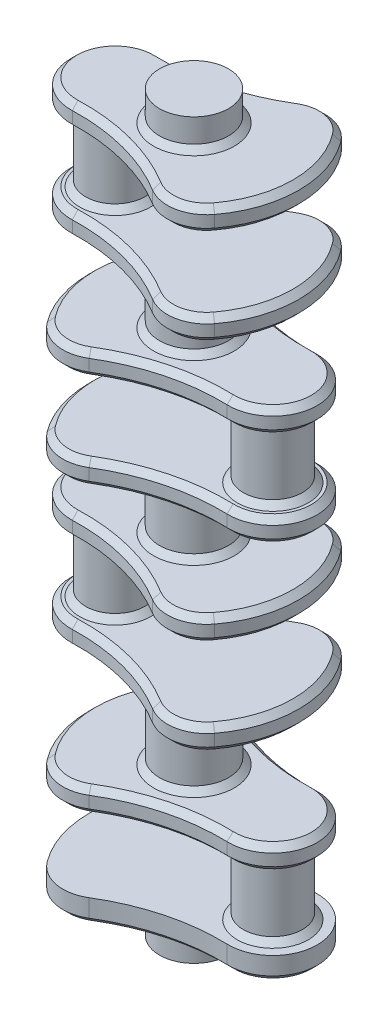
from build123d import *

# Parameters (mm, degrees)
SALIENTE_EXTRUIR1_DEPTH  = 12
CROQUIS3_R               = 17.5
SALIENTE_EXTRUIR2_DEPTH  = 15
SALIENTE_EXTRUIR3_DEPTH  = 12
CROQUIS6_R               = 15
SALIENTE_EXTRUIR4_DEPTH  = 36
SALIENTE_EXTRUIR6_DEPTH  = 12
CROQUIS9_R               = 17.5
SALIENTE_EXTRUIR7_DEPTH  = 42
SALIENTE_EXTRUIR8_DEPTH  = 12
CROQUIS11_R              = 15
SALIENTE_EXTRUIR10_DEPTH = 36
SALIENTE_EXTRUIR11_DEPTH = 12
CROQUIS13_R              = 17.5
SALIENTE_EXTRUIR12_DEPTH = 30
SALIENTE_EXTRUIR13_DEPTH = 12
CROQUIS15_R              = 15
SALIENTE_EXTRUIR14_DEPTH = 36
SALIENTE_EXTRUIR16_DEPTH = 12
CROQUIS18_R              = 17.5
SALIENTE_EXTRUIR17_DEPTH = 30
SALIENTE_EXTRUIR18_DEPTH = 12
CROQUIS20_R              = 15
SALIENTE_EXTRUIR19_DEPTH = 36
CROQUIS21_R              = 17.5
SALIENTE_EXTRUIR20_DEPTH = 15
CHAFL_N2_SIZE            = 3


with BuildPart() as part:
    # Croquis2 → Saliente-Extruir1 (new body)
    with BuildSketch(Plane(origin=(0, 0, 0), x_dir=(1, 0, 0), z_dir=(0, 1, 0))):
        with BuildLine():
            ThreePointArc((-16.08221071, 37.072482722), (-30.241727041, 39.646869439), (-42.463783007, 32.048138118))
            ThreePointArc((-42.463783007, 32.048138118), (-53.200150602, 0), (-42.463783007, -32.048138118))
            ThreePointArc((-42.463783007, -32.048138118), (-30.241727041, -39.646869439), (-16.08221071, -37.072482722))
            ThreePointArc((-16.08221071, -37.072482722), (10.526396699, -25.735608218), (39.266543299, -22.488042184))
            ThreePointArc((39.266543299, -22.488042184), (62.5, 0), (39.266543299, 22.488042184))
            ThreePointArc((39.266543299, 22.488042184), (10.526396699, 25.735608218), (-16.08221071, 37.072482722))
        make_face()
    extrude(amount=SALIENTE_EXTRUIR1_DEPTH)

    # Croquis3 → Saliente-Extruir2 (add)
    with BuildSketch(Plane.XZ):
        Circle(CROQUIS3_R)
    extrude(amount=SALIENTE_EXTRUIR2_DEPTH)



with BuildPart() as body_2:
    # Croquis4 → Saliente-Extruir3 (new body)
    with BuildSketch(Plane(origin=(0, 48, 0), x_dir=(1, 0, 0), z_dir=(0, 1, 0))):
        with BuildLine():
            ThreePointArc((-16.08221071, 37.072482722), (-30.241727041, 39.646869439), (-42.463783007, 32.048138118))
            ThreePointArc((-42.463783007, 32.048138118), (-53.200150602, 0), (-42.463783007, -32.048138118))
            ThreePointArc((-42.463783007, -32.048138118), (-30.241727041, -39.646869439), (-16.08221071, -37.072482722))
            ThreePointArc((-16.08221071, -37.072482722), (10.526396699, -25.735608218), (39.266543299, -22.488042184))
            ThreePointArc((39.266543299, -22.488042184), (62.5, 0), (39.266543299, 22.488042184))
            ThreePointArc((39.266543299, 22.488042184), (10.526396699, 25.735608218), (-16.08221071, 37.072482722))
        make_face()
    extrude(amount=SALIENTE_EXTRUIR3_DEPTH)


with BuildPart() as part_1:
    add(part.part)

    add(body_2.part)  # Saliente-Extruir4 merges body 2
    # Croquis6 → Saliente-Extruir4 (add)
    with BuildSketch(Plane(origin=(0, 48, 0), x_dir=(-1, 0, 0), z_dir=(0, -1, 0))):
        with Locations((-40, 0)):
            Circle(CROQUIS6_R)
    extrude(amount=SALIENTE_EXTRUIR4_DEPTH)



with BuildPart() as body_2_2:
    # Croquis8 → Saliente-Extruir6 (new body)
    with BuildSketch(Plane(origin=(0, 102, 0), x_dir=(1, 0, 0), z_dir=(0, 1, 0))):
        with BuildLine():
            ThreePointArc((-39.266543299, 22.488042184), (-62.5, 0), (-39.266543299, -22.488042184))
            ThreePointArc((-39.266543299, -22.488042184), (-10.526396699, -25.735608218), (16.08221071, -37.072482722))
            ThreePointArc((16.08221071, -37.072482722), (30.241727041, -39.646869439), (42.463783007, -32.048138118))
            ThreePointArc((42.463783007, -32.048138118), (53.200150602, 0), (42.463783007, 32.048138118))
            ThreePointArc((42.463783007, 32.048138118), (30.241727041, 39.646869439), (16.08221071, 37.072482722))
            ThreePointArc((16.08221071, 37.072482722), (-10.526396699, 25.735608218), (-39.266543299, 22.488042184))
        make_face()
    extrude(amount=SALIENTE_EXTRUIR6_DEPTH)


with BuildPart() as part_2:
    add(part_1.part)

    add(body_2_2.part)  # Saliente-Extruir7 merges body 2 2
    # Croquis9 → Saliente-Extruir7 (add)
    with BuildSketch(Plane.XZ.offset(-102)):
        Circle(CROQUIS9_R)
    extrude(amount=SALIENTE_EXTRUIR7_DEPTH)



with BuildPart() as body_2_3:
    # Croquis10 → Saliente-Extruir8 (new body)
    with BuildSketch(Plane(origin=(0, 150, 0), x_dir=(-1, 0, 0), z_dir=(0, -1, 0))):
        with BuildLine():
            ThreePointArc((-42.463783007, 32.048138118), (-53.200150602, 0), (-42.463783007, -32.048138118))
            ThreePointArc((-42.463783007, -32.048138118), (-30.241727041, -39.646869439), (-16.08221071, -37.072482722))
            ThreePointArc((-16.08221071, -37.072482722), (10.526396699, -25.735608218), (39.266543299, -22.488042184))
            ThreePointArc((39.266543299, -22.488042184), (62.5, 0), (39.266543299, 22.488042184))
            ThreePointArc((39.266543299, 22.488042184), (10.526396699, 25.735608218), (-16.08221071, 37.072482722))
            ThreePointArc((-16.08221071, 37.072482722), (-30.241727041, 39.646869439), (-42.463783007, 32.048138118))
        make_face()
    extrude(amount=-SALIENTE_EXTRUIR8_DEPTH)


with BuildPart() as part_3:
    add(part_2.part)

    add(body_2_3.part)  # Saliente-Extruir10 merges body 2 3
    # Croquis11 → Saliente-Extruir10 (add)
    with BuildSketch(Plane.XZ.offset(-150)):
        with Locations((-40, 0)):
            Circle(CROQUIS11_R)
    extrude(amount=SALIENTE_EXTRUIR10_DEPTH)



with BuildPart() as body_2_4:
    # Croquis12 → Saliente-Extruir11 (new body)
    with BuildSketch(Plane(origin=(0, 192, 0), x_dir=(-1, 0, 0), z_dir=(0, -1, 0))):
        with BuildLine():
            ThreePointArc((-39.266543299, 22.488042184), (-10.526396699, 25.735608218), (16.08221071, 37.072482722))
            ThreePointArc((16.08221071, 37.072482722), (30.241727041, 39.646869439), (42.463783007, 32.048138118))
            ThreePointArc((42.463783007, 32.048138118), (53.200150602, 0), (42.463783007, -32.048138118))
            ThreePointArc((42.463783007, -32.048138118), (30.241727041, -39.646869439), (16.08221071, -37.072482722))
            ThreePointArc((16.08221071, -37.072482722), (-10.526396699, -25.735608218), (-39.266543299, -22.488042184))
            ThreePointArc((-39.266543299, -22.488042184), (-62.5, 0), (-39.266543299, 22.488042184))
        make_face()
    extrude(amount=-SALIENTE_EXTRUIR11_DEPTH)


with BuildPart() as part_4:
    add(part_3.part)

    add(body_2_4.part)  # Saliente-Extruir12 merges body 2 4
    # Croquis13 → Saliente-Extruir12 (add)
    with BuildSketch(Plane.XZ.offset(-192)):
        Circle(CROQUIS13_R)
    extrude(amount=SALIENTE_EXTRUIR12_DEPTH)



with BuildPart() as body_2_5:
    # Croquis14 → Saliente-Extruir13 (new body)
    with BuildSketch(Plane(origin=(0, 240, 0), x_dir=(-1, 0, 0), z_dir=(0, -1, 0))):
        with BuildLine():
            ThreePointArc((-39.266543299, 22.488042184), (-62.5, 0), (-39.266543299, -22.488042184))
            ThreePointArc((-39.266543299, -22.488042184), (-10.526396699, -25.735608218), (16.08221071, -37.072482722))
            ThreePointArc((16.08221071, -37.072482722), (30.241727041, -39.646869439), (42.463783007, -32.048138118))
            ThreePointArc((42.463783007, -32.048138118), (53.200150602, 0), (42.463783007, 32.048138118))
            ThreePointArc((42.463783007, 32.048138118), (30.241727041, 39.646869439), (16.08221071, 37.072482722))
            ThreePointArc((16.08221071, 37.072482722), (-10.526396699, 25.735608218), (-39.266543299, 22.488042184))
        make_face()
    extrude(amount=-SALIENTE_EXTRUIR13_DEPTH)


with BuildPart() as part_5:
    add(part_4.part)

    add(body_2_5.part)  # Saliente-Extruir14 merges body 2 5
    # Croquis15 → Saliente-Extruir14 (add)
    with BuildSketch(Plane.XZ.offset(-240)):
        with Locations((40, 0)):
            Circle(CROQUIS15_R)
    extrude(amount=SALIENTE_EXTRUIR14_DEPTH)



with BuildPart() as body_2_6:
    # Croquis17 → Saliente-Extruir16 (new body)
    with BuildSketch(Plane(origin=(0, 282, 0), x_dir=(-1, 0, 0), z_dir=(0, -1, 0))):
        with BuildLine():
            ThreePointArc((-16.08221071, 37.072482722), (-30.241727041, 39.646869439), (-42.463783007, 32.048138118))
            ThreePointArc((-42.463783007, 32.048138118), (-53.200150602, 0), (-42.463783007, -32.048138118))
            ThreePointArc((-42.463783007, -32.048138118), (-30.241727041, -39.646869439), (-16.08221071, -37.072482722))
            ThreePointArc((-16.08221071, -37.072482722), (10.526396699, -25.735608218), (39.266543299, -22.488042184))
            ThreePointArc((39.266543299, -22.488042184), (62.5, 0), (39.266543299, 22.488042184))
            ThreePointArc((39.266543299, 22.488042184), (10.526396699, 25.735608218), (-16.08221071, 37.072482722))
        make_face()
    extrude(amount=-SALIENTE_EXTRUIR16_DEPTH)


with BuildPart() as part_6:
    add(part_5.part)

    add(body_2_6.part)  # Saliente-Extruir17 merges body 2 6
    # Croquis18 → Saliente-Extruir17 (add)
    with BuildSketch(Plane.XZ.offset(-282)):
        Circle(CROQUIS18_R)
    extrude(amount=SALIENTE_EXTRUIR17_DEPTH)



with BuildPart() as body_2_7:
    # Croquis19 → Saliente-Extruir18 (new body)
    with BuildSketch(Plane(origin=(0, 330, 0), x_dir=(-1, 0, 0), z_dir=(0, -1, 0))):
        with BuildLine():
            ThreePointArc((-16.08221071, 37.072482722), (10.526396699, 25.735608218), (39.266543299, 22.488042184))
            ThreePointArc((39.266543299, 22.488042184), (62.5, 0), (39.266543299, -22.488042184))
            ThreePointArc((39.266543299, -22.488042184), (10.526396699, -25.735608218), (-16.08221071, -37.072482722))
            ThreePointArc((-16.08221071, -37.072482722), (-30.241727041, -39.646869439), (-42.463783007, -32.048138118))
            ThreePointArc((-42.463783007, -32.048138118), (-53.200150602, 0), (-42.463783007, 32.048138118))
            ThreePointArc((-42.463783007, 32.048138118), (-30.241727041, 39.646869439), (-16.08221071, 37.072482722))
        make_face()
    extrude(amount=-SALIENTE_EXTRUIR18_DEPTH)


with BuildPart() as part_7:
    add(part_6.part)

    add(body_2_7.part)  # Saliente-Extruir19 merges body 2 7
    # Croquis20 → Saliente-Extruir19 (add)
    with BuildSketch(Plane.XZ.offset(-330)):
        with Locations((-40, 0)):
            Circle(CROQUIS20_R)
    extrude(amount=SALIENTE_EXTRUIR19_DEPTH)

    # Croquis21 → Saliente-Extruir20 (add)
    with BuildSketch(Plane(origin=(0, 342, 0), x_dir=(1, 0, 0), z_dir=(0, 1, 0))):
        Circle(CROQUIS21_R)
    extrude(amount=SALIENTE_EXTRUIR20_DEPTH)

    # Chaflán2
    chafl_n2_edges = [part_7.edges().sort_by_distance(p)[0] for p in [
        (-17.5, 252, 0),
        (-10.526396699, 282, -25.735608218),
        (30.241727041, 282, -39.646869439),
        (53.200150602, 282, 0),
        (30.241727041, 282, 39.646869439),
        (-10.526396699, 282, 25.735608218),
        (-62.5, 282, 0),
        (-10.526396699, 294, -25.735608218),
        (-62.5, 294, 0),
        (-10.526396699, 294, 25.735608218),
        (30.241727041, 294, 39.646869439),
        (53.200150602, 294, 0),
        (30.241727041, 294, -39.646869439),
        (-17.5, 282, 0),
        (-55, 294, 0),
        (30.241727041, 330, -39.646869439),
        (53.200150602, 330, 0),
        (30.241727041, 330, 39.646869439),
        (-10.526396699, 330, 25.735608218),
        (-62.5, 330, 0),
        (-10.526396699, 330, -25.735608218),
        (30.241727041, 342, -39.646869439),
        (-10.526396699, 342, -25.735608218),
        (-62.5, 342, 0),
        (-10.526396699, 342, 25.735608218),
        (30.241727041, 342, 39.646869439),
        (53.200150602, 342, 0),
        (-55, 330, 0),
        (-17.5, 342, 0),
        (-17.5, 0, 0),
        (55, 12, 0),
        (55, 48, 0),
        (10.526396699, 48, -25.735608218),
        (-30.241727041, 48, -39.646869439),
        (-53.200150602, 48, 0),
        (-30.241727041, 48, 39.646869439),
        (10.526396699, 48, 25.735608218),
        (62.5, 48, 0),
        (10.526396699, 60, -25.735608218),
        (-30.241727041, 60, -39.646869439),
        (-53.200150602, 60, 0),
        (-30.241727041, 60, 39.646869439),
        (10.526396699, 60, 25.735608218),
        (62.5, 60, 0),
        (-17.5, 60, 0),
        (-17.5, 102, 0),
        (-10.526396699, 102, -25.735608218),
        (-62.5, 102, 0),
        (-10.526396699, 102, 25.735608218),
        (30.241727041, 102, 39.646869439),
        (53.200150602, 102, 0),
        (30.241727041, 102, -39.646869439),
        (-10.526396699, 114, -25.735608218),
        (-62.5, 114, 0),
        (-10.526396699, 114, 25.735608218),
        (30.241727041, 114, 39.646869439),
        (53.200150602, 114, 0),
        (30.241727041, 114, -39.646869439),
        (-55, 114, 0),
        (30.241727041, 150, -39.646869439),
        (53.200150602, 150, 0),
        (30.241727041, 150, 39.646869439),
        (-10.526396699, 150, 25.735608218),
        (-62.5, 150, 0),
        (-10.526396699, 150, -25.735608218),
        (30.241727041, 162, -39.646869439),
        (-10.526396699, 162, -25.735608218),
        (-62.5, 162, 0),
        (-10.526396699, 162, 25.735608218),
        (30.241727041, 162, 39.646869439),
        (53.200150602, 162, 0),
        (-55, 150, 0),
        (-30.241727041, 0, -39.646869439),
        (10.526396699, 0, -25.735608218),
        (62.5, 0, 0),
        (-17.5, 162, 0),
        (10.526396699, 0, 25.735608218),
        (62.5, 192, 0),
        (10.526396699, 192, 25.735608218),
        (-30.241727041, 192, 39.646869439),
        (-53.200150602, 192, 0),
        (-30.241727041, 192, -39.646869439),
        (10.526396699, 192, -25.735608218),
        (62.5, 204, 0),
        (10.526396699, 204, -25.735608218),
        (-30.241727041, 204, -39.646869439),
        (-53.200150602, 204, 0),
        (-30.241727041, 204, 39.646869439),
        (10.526396699, 204, 25.735608218),
        (-30.241727041, 0, 39.646869439),
        (-17.5, 192, 0),
        (-53.200150602, 0, 0),
        (25, 204, 0),
        (10.526396699, 240, -25.735608218),
        (62.5, 240, 0),
        (10.526396699, 240, 25.735608218),
        (-30.241727041, 240, 39.646869439),
        (-53.200150602, 240, 0),
        (-30.241727041, 240, -39.646869439),
        (10.526396699, 252, -25.735608218),
        (-30.241727041, 252, -39.646869439),
        (-53.200150602, 252, 0),
        (-30.241727041, 252, 39.646869439),
        (10.526396699, 252, 25.735608218),
        (62.5, 252, 0),
        (25, 240, 0),
    ]]
    chamfer(chafl_n2_edges, length=CHAFL_N2_SIZE)


solid = part_7.part
